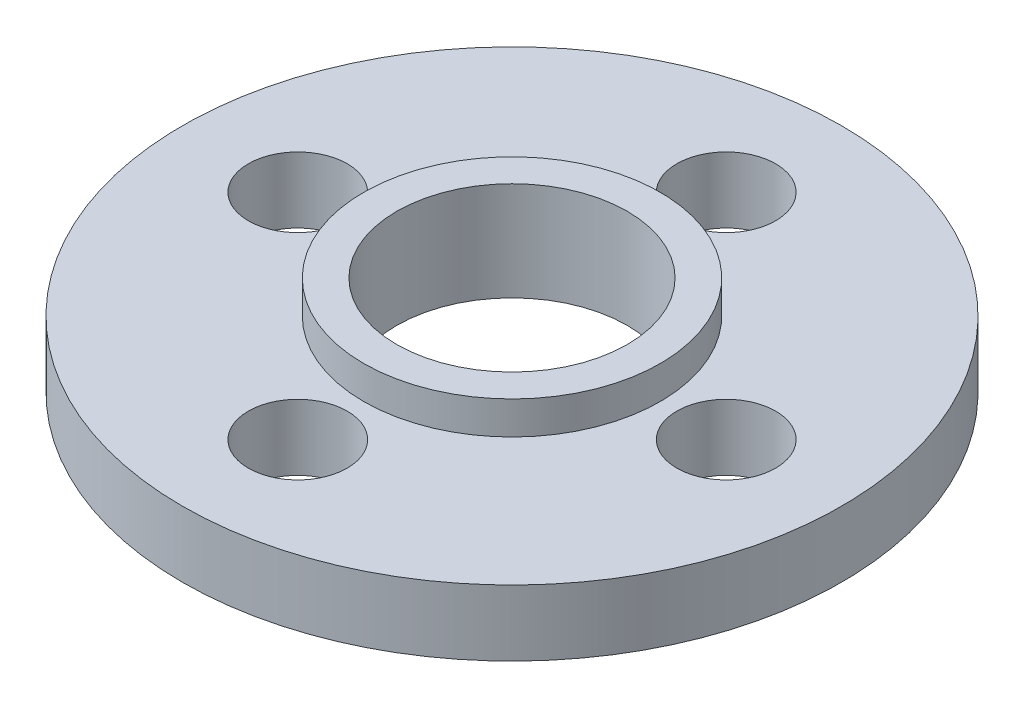
from build123d import *

# Parameters (mm, degrees)
SKETCH_1_R          = 10
SKETCH_1_R_2        = 3.5
SKETCH_1_R_3        = 1.5
EXTRUDE_1_DEPTH     = 3
SKETCH_2_R          = 10
SKETCH_2_R_2        = 4.5
SKETCH_2_R_3        = 1.5
CUT_EXTRUDE_1_DEPTH = 1


with BuildPart() as part:
    # 草图1 → 凸台-拉伸1 (new body)
    with BuildSketch(Plane(origin=(0, 0, 0), x_dir=(1, 0, 0), z_dir=(0, 1, 0))):
        Circle(SKETCH_1_R)
        Circle(SKETCH_1_R_2, mode=Mode.SUBTRACT)
        with Locations((0, 6.5)):
            Circle(SKETCH_1_R_3, mode=Mode.SUBTRACT)
        with Locations((0, -6.5)):
            Circle(SKETCH_1_R_3, mode=Mode.SUBTRACT)
        with Locations((-6.5, 0)):
            Circle(SKETCH_1_R_3, mode=Mode.SUBTRACT)
        with Locations((6.5, 0)):
            Circle(SKETCH_1_R_3, mode=Mode.SUBTRACT)
    extrude(amount=EXTRUDE_1_DEPTH)

    # 草图2 → 切除-拉伸1 (cut)
    with BuildSketch(Plane(origin=(0, 3, 0), x_dir=(1, 0, 0), z_dir=(0, 1, 0))):
        Circle(SKETCH_2_R)
        Circle(SKETCH_2_R_2, mode=Mode.SUBTRACT)
        with Locations((0, -6.5)):
            Circle(SKETCH_2_R_3, mode=Mode.SUBTRACT)
        with Locations((0, 6.5)):
            Circle(SKETCH_2_R_3, mode=Mode.SUBTRACT)
        with Locations((6.5, 0)):
            Circle(SKETCH_2_R_3, mode=Mode.SUBTRACT)
        with Locations((-6.5, 0)):
            Circle(SKETCH_2_R_3, mode=Mode.SUBTRACT)
    extrude(amount=-CUT_EXTRUDE_1_DEPTH, mode=Mode.SUBTRACT)


solid = part.part
